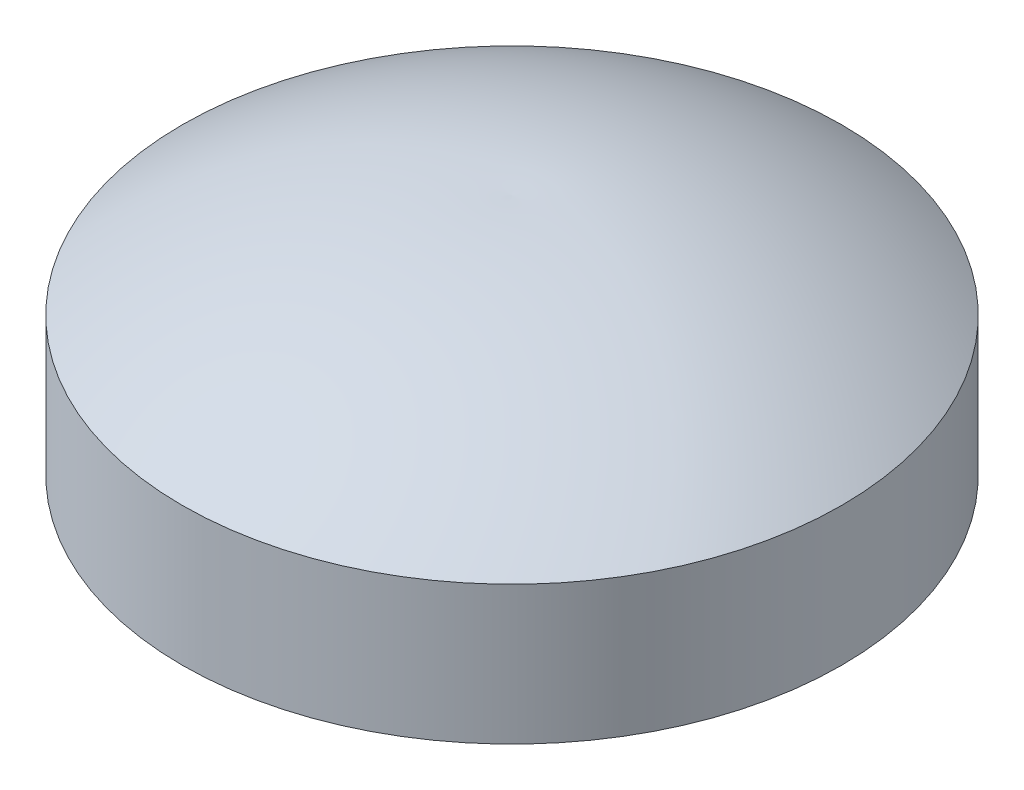
from build123d import *


with BuildPart() as part:
    # Sketch1 → Revolve1 (revolve)
    with BuildSketch(Plane.XY):
        with BuildLine():
            Line((0, 0), (4.7625, 0))
            Line((4.7625, 0), (4.7625, 2))
            add(Edge.make_bspline(
                [(0, 3.5), (2.471284121, 3.60432663), (4.7625, 2)],
                knots=[0, 0, 0, 1, 1, 1], degree=2))
            Line((0, 3.5), (0, 0))
        make_face()
    revolve(axis=Axis((0, 0, 0), (0, 1, 0)))


solid = part.part
